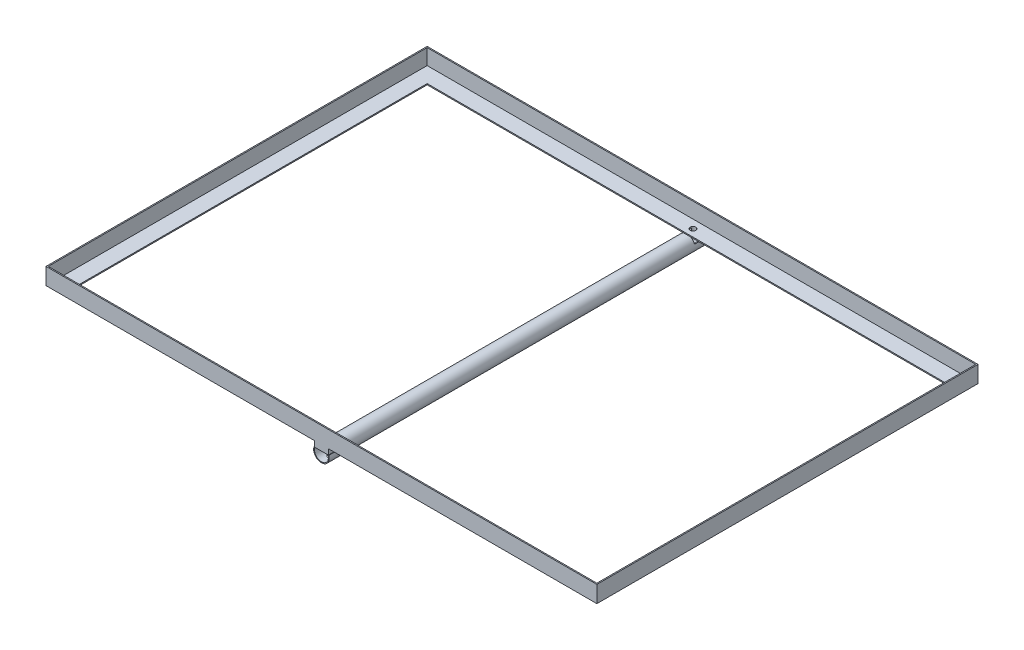
from build123d import *

# Parameters (mm, degrees)
SKETCH2_R            = 14
SKETCH2_R_2          = 12.5
BOSS_EXTRUDE3_DEPTH  = 800
SKETCH3_W            = 50.702600358
SKETCH3_H            = 14.280844995
CUT_EXTRUDE2_DEPTH   = 800
SKETCH5_W            = 25
SKETCH5_H            = 30
BOSS_EXTRUDE4_DEPTH  = 10
SKETCH7_W            = 990
SKETCH7_H            = 685
SKETCH7_W_2          = 930
SKETCH7_H_2          = 625
BOSS_EXTRUDE7_DEPTH  = 30
SKETCH8_W            = 986
SKETCH8_H            = 681
CUT_EXTRUDE3_DEPTH   = 28
SKETCH9_R            = 5
CUT_EXTRUDE4_DEPTH   = 40
SKETCH15_W           = 1140
SKETCH15_H           = 860
SKETCH15_W_2         = 980
SKETCH15_H_2         = 700
CUT_EXTRUDE6_DEPTH   = 149
SKETCH17_W           = 10
SKETCH17_H           = 2
BOSS_EXTRUDE11_DEPTH = 685
SKETCH20_W           = 25
SKETCH20_H           = 15
CUT_EXTRUDE7_DEPTH   = 38
SKETCH22_R           = 14
SKETCH22_R_2         = 12.5
BOSS_EXTRUDE13_DEPTH = 627
SKETCH23_W           = 59.046620232
SKETCH23_H           = 45.176343133
CUT_EXTRUDE8_DEPTH   = 627


with BuildPart() as part:
    # Sketch2 → Boss-Extrude3 (new body)
    with BuildSketch(Plane.XY):
        with Locations((-96.233955608, 31.778750266)):
            Circle(SKETCH2_R)
        with Locations((-96.233955608, 31.778750266)):
            Circle(SKETCH2_R_2, mode=Mode.SUBTRACT)
    extrude(amount=BOSS_EXTRUDE3_DEPTH)

    # Sketch3 → Cut-Extrude2 (cut)
    with BuildSketch(Plane.XY.offset(800)):
        with Locations((-97.127751448, 43.123650815)):
            Rectangle(SKETCH3_W, SKETCH3_H)
    extrude(amount=-CUT_EXTRUDE2_DEPTH, mode=Mode.SUBTRACT)

    # Sketch5 → Boss-Extrude4 (add)
    with BuildSketch(Plane(origin=(0, 35.983228318, 0), x_dir=(1, 0, 0), z_dir=(0, 1, 0))):
        with Locations((-96.233955608, -65)):
            Rectangle(SKETCH5_W, SKETCH5_H)
        with Locations((-96.233955608, -735)):
            Rectangle(SKETCH5_W, SKETCH5_H)
    extrude(amount=BOSS_EXTRUDE4_DEPTH)

    # Sketch7 → Boss-Extrude7 (add)
    with BuildSketch(Plane(origin=(0, 45.983228318, 0), x_dir=(1, 0, 0), z_dir=(0, 1, 0))):
        with Locations((-96.233955608, -407.5)):
            Rectangle(SKETCH7_W, SKETCH7_H)
        with Locations((-96.233955608, -407.5)):
            Rectangle(SKETCH7_W_2, SKETCH7_H_2, mode=Mode.SUBTRACT)
    extrude(amount=BOSS_EXTRUDE7_DEPTH)

    # Sketch8 → Cut-Extrude3 (cut)
    with BuildSketch(Plane(origin=(0, 75.983228318, 0), x_dir=(1, 0, 0), z_dir=(0, 1, 0))):
        with Locations((-96.233955608, -407.5)):
            Rectangle(SKETCH8_W, SKETCH8_H)
    extrude(amount=-CUT_EXTRUDE3_DEPTH, mode=Mode.SUBTRACT)

    # Sketch9 → Cut-Extrude4 (cut)
    with BuildSketch(Plane(origin=(0, 47.983228318, 0), x_dir=(1, 0, 0), z_dir=(0, 1, 0))):
        with Locations((-96.432449353, -82)):
            Circle(SKETCH9_R)
        with Locations((-96.432449353, -733)):
            Circle(SKETCH9_R)
    extrude(amount=-CUT_EXTRUDE4_DEPTH, mode=Mode.SUBTRACT)

    # Sketch15 → Cut-Extrude6 (cut)
    with BuildSketch(Plane(origin=(0, 47.983228318, 0), x_dir=(1, 0, 0), z_dir=(0, 1, 0))):
        with Locations((-91.233955608, -400)):
            Rectangle(SKETCH15_W, SKETCH15_H)
        with Locations((-91.233955608, -400)):
            Rectangle(SKETCH15_W_2, SKETCH15_H_2, mode=Mode.SUBTRACT)
    extrude(amount=-CUT_EXTRUDE6_DEPTH, mode=Mode.SUBTRACT)

    # Sketch17 → Boss-Extrude11 (add)
    with BuildSketch(Plane.XY.offset(750)):
        with Locations((-586.233955608, 46.983228318)):
            Rectangle(SKETCH17_W, SKETCH17_H)
    extrude(amount=-BOSS_EXTRUDE11_DEPTH)

    # Sketch20 → Cut-Extrude7 (cut)
    with BuildSketch(Plane(origin=(0, 45.983228318, 0), x_dir=(1, 0, 0), z_dir=(0, 1, 0))):
        with Locations((-96.233955608, -57.5)):
            Rectangle(SKETCH20_W, SKETCH20_H)
    extrude(amount=-CUT_EXTRUDE7_DEPTH, mode=Mode.SUBTRACT)

    # Sketch22 → Boss-Extrude13 (add)
    with BuildSketch(Plane(origin=(0, 0, 720), x_dir=(-1, 0, 0), z_dir=(0, 0, -1))):
        with Locations((96.233955608, 31.778750266)):
            Circle(SKETCH22_R)
        with Locations((96.233955608, 31.778750266)):
            Circle(SKETCH22_R_2, mode=Mode.SUBTRACT)
    extrude(amount=BOSS_EXTRUDE13_DEPTH)

    # Sketch23 → Cut-Extrude8 (cut)
    with BuildSketch(Plane(origin=(0, 47.983228318, 0), x_dir=(1, 0, 0), z_dir=(0, 1, 0))):
        with Locations((-102.636866369, -42.411828433)):
            Rectangle(SKETCH23_W, SKETCH23_H)
    extrude(amount=-CUT_EXTRUDE8_DEPTH, mode=Mode.SUBTRACT)


solid = part.part
